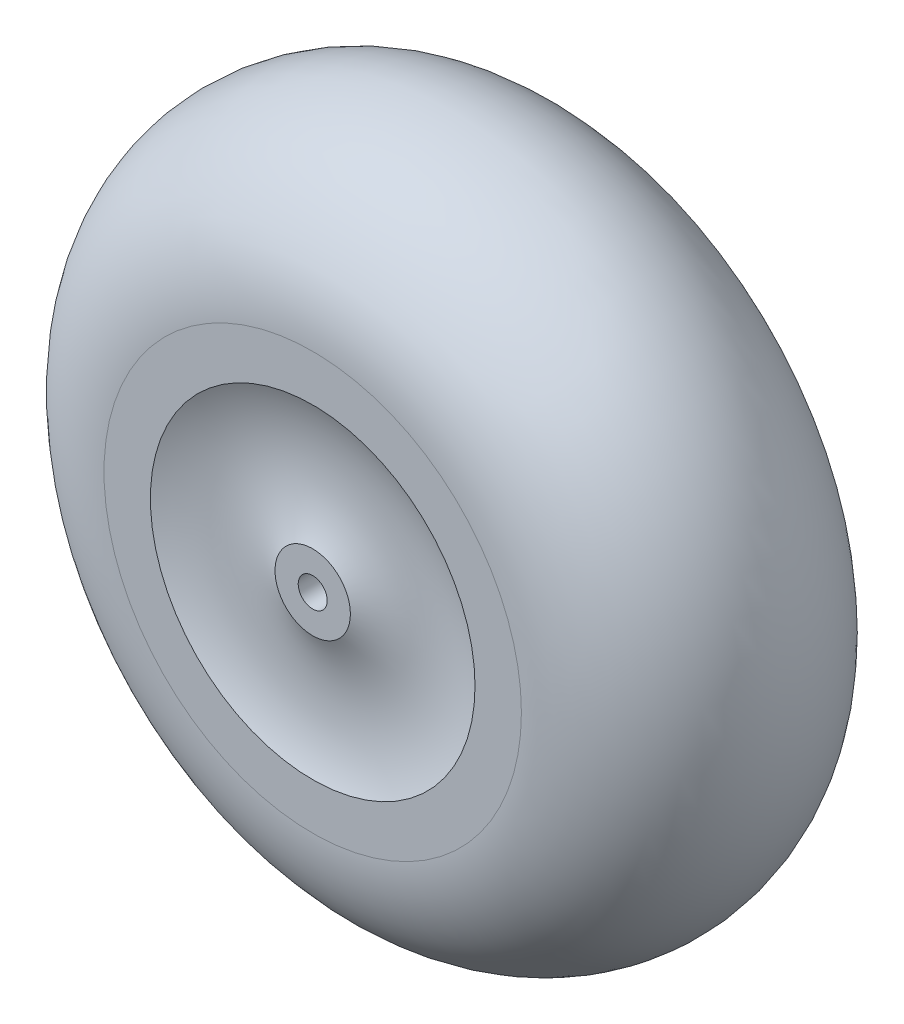
from build123d import *


with BuildPart() as part:
    # Sketch1 → Revolve1 (revolve)
    with BuildSketch(Plane(origin=(0, 0, 0), x_dir=(1, 0, 0), z_dir=(0, 1, 0))):
        with BuildLine():
            Line((-7.9375, -25.4), (-7.9375, 25.4))
            Line((-7.9375, 25.4), (-20.6375, 25.4))
            Line((-20.6375, 25.4), (-20.6375, -19.05))
            ThreePointArc((-20.6375, -19.05), (-54.768750138, -11.463041765), (-88.900000276, -19.05))
            Line((-88.900000276, -19.05), (-88.900000276, 126.999998896))
            Line((-88.900000276, 126.999998896), (-114.312969887, 126.999998896))
            ThreePointArc((-114.312969887, 126.999998896), (-190.5, 50.793515194), (-114.300000276, -25.4))
            Line((-114.300000276, -25.4), (-88.900000276, -25.4))
            ThreePointArc((-88.900000276, -25.4), (-54.768750138, -17.813041765), (-20.6375, -25.4))
            Line((-20.6375, -25.4), (-7.9375, -25.4))
        make_face()
    revolve(axis=Axis((0, 0, 25.4), (0, 0, -1)))


solid = part.part
